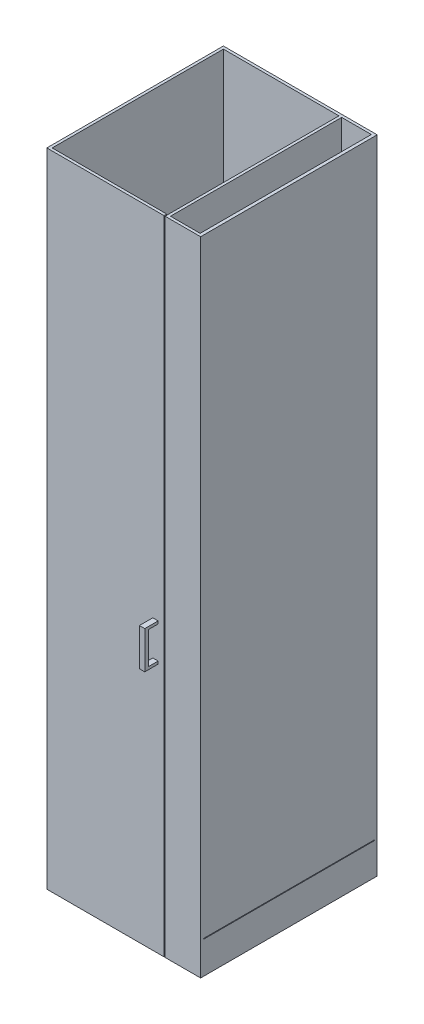
from build123d import *

# Parameters (mm, degrees)
BOSS_EXTRUDE1_DEPTH    = 1200
BOSS_EXTRUDE2_DEPTH    = 320
CUT_EXTRUDE2_START     = 0.5
SKETCH6_W              = 165
SKETCH6_H              = 60
CUT_EXTRUDE2_DEPTH     = 10
BOSS_EXTRUDE14_DEPTH   = 15
LPATTERN1_COUNT        = 2
LPATTERN1_PITCH        = 136
LPATTERN2_COUNT        = 2
LPATTERN2_PITCH        = 75
LPATTERN2_COPY_1_DEPTH = 15
CUT_EXTRUDE5_START     = 70
SKETCH14_R             = 2.5
CUT_EXTRUDE5_DEPTH     = 80
BOSS_EXTRUDE19_DEPTH   = 320
CUT_EXTRUDE10_DEPTH    = 320
BOSS_EXTRUDE20_DEPTH   = 320
CUT_EXTRUDE11_DEPTH    = 320
CUT_EXTRUDE12_DEPTH    = 320
SKETCH32_W             = 66.375164862
SKETCH32_H             = 1200
BOSS_EXTRUDE21_DEPTH   = 5
SKETCH33_W             = 219.088897638
SKETCH33_H             = 1200
BOSS_EXTRUDE23_DEPTH   = 5
SKETCH34_W             = 10
SKETCH34_H             = 70
BOSS_EXTRUDE24_DEPTH   = 30
CUT_EXTRUDE13_REACH    = 91.42
SKETCH35_W             = 18
SKETCH35_H             = 60


with BuildPart() as part:
    # Sketch1 → Boss-Extrude1 (new body)
    with BuildSketch(Plane(origin=(0, 0, 0), x_dir=(1, 0, 0), z_dir=(0, 1, 0))):
        Polygon((-138.29, -160), (-143.29, -160), (-143.29, 165), (144.1740625, 165), (144.1740625, -160), (138.29, -160), (138.29, 160), (-138.29, 160), align=None)
    extrude(amount=BOSS_EXTRUDE1_DEPTH)

    # Sketch3 → Boss-Extrude2 (add)
    with BuildSketch(Plane.XY.offset(-160)):
        Polygon((138.29, 50), (-138.29, 178.971372093), (-138.29, 188.971372093), (138.29, 60), align=None)
    extrude(amount=BOSS_EXTRUDE2_DEPTH)

    # Sketch6 → Cut-Extrude2 (cut)
    with BuildSketch(Plane(origin=(47.680784022, 102.25177131, 0), x_dir=(0.906307787, -0.422618262, 0), z_dir=(0.422618262, 0.906307787, 0)).offset(CUT_EXTRUDE2_START)):
        with Locations((-3.631700195, 0)):
            Rectangle(SKETCH6_W, SKETCH6_H)
    extrude(amount=-CUT_EXTRUDE2_DEPTH, mode=Mode.SUBTRACT)

    # Sketch15 → Boss-Extrude14 (add)
    with BuildSketch(Plane.XY.offset(-30)):
        Polygon((-30.960803737, 128.922945932), (-12.411066849, 120.273061564), (-12.411066849, 105.273061564), (-30.960803737, 113.922945932), align=None)
    boss_extrude14 = extrude(amount=-BOSS_EXTRUDE14_DEPTH)

    # LPattern1: Boss-Extrude14 ×2
    with Locations(*[Vector(0.906307787, -0.422618262, 0) * (i * LPATTERN1_PITCH) for i in range(1, LPATTERN1_COUNT)]):
        add(boss_extrude14)

    # LPattern2: Boss-Extrude14 ×2
    with Locations(*[(0, 0, i * LPATTERN2_PITCH) for i in range(1, LPATTERN2_COUNT)]):
        add(boss_extrude14)

    # LPattern2 copy 1 sketch → LPattern2 copy 1 (add)
    with BuildSketch(Plane(origin=(123.257859037, -57.476083597, 45), x_dir=(1, 0, 0), z_dir=(0, 0, 1))):
        Polygon((-30.960803737, 128.922945932), (-12.411066849, 120.273061564), (-12.411066849, 105.273061564), (-30.960803737, 113.922945932), align=None)
    extrude(amount=-LPATTERN2_COPY_1_DEPTH)

    # Sketch14 → Cut-Extrude5 (cut)
    with BuildSketch(Plane.XY.offset(-30).offset(CUT_EXTRUDE5_START)):
        with Locations((-22.522311936, 121.195788594)):
            Circle(SKETCH14_R)
        with Locations((100.735547101, 63.719704997)):
            Circle(SKETCH14_R)
    extrude(amount=-CUT_EXTRUDE5_DEPTH, mode=Mode.SUBTRACT)

    # Sketch19 → Boss-Extrude19 (add)
    with BuildSketch(Plane.XY.offset(-160)):
        Polygon((82.798897638, 85.875925991), (82.798897638, 1200), (77.798897638, 1200), (77.798897638, 88.207464282), align=None)
    extrude(amount=BOSS_EXTRUDE19_DEPTH)

    # Sketch27 → Cut-Extrude10 (cut)
    with BuildSketch(Plane.XY.offset(160)):
        Polygon((77.798897638, 97.590680412), (82.798897638, 95.259142121), (82.798897638, 85.875925991), (77.798897638, 88.715225589), align=None)
    extrude(amount=-CUT_EXTRUDE10_DEPTH, mode=Mode.SUBTRACT)

    # Sketch28 → Boss-Extrude20 (add)
    with BuildSketch(Plane.XY.offset(160)):
        Polygon((77.798897638, 97.590680412), (83.146994647, 87.403232752), (82.798897638, 95.259142121), align=None)
    extrude(amount=-BOSS_EXTRUDE20_DEPTH)

    # Sketch29 → Cut-Extrude11 (cut)
    with BuildSketch(Plane.XY.offset(160)):
        Polygon((138.29, 60), (138.29, 63), (144.1740625, 61.2), (144.1740625, 60), align=None)
    extrude(amount=-CUT_EXTRUDE11_DEPTH, mode=Mode.SUBTRACT)

    # Sketch31 → Cut-Extrude12 (cut)
    with BuildSketch(Plane.XY.offset(160)):
        Polygon((77.798897638, 88.207464282), (82.798897638, 85.875925991), (77.798897638, 88.715225589), align=None)
    extrude(amount=-CUT_EXTRUDE12_DEPTH, mode=Mode.SUBTRACT)

    # Sketch32 → Boss-Extrude21 (add)
    with BuildSketch(Plane.XY.offset(160)):
        with Locations((110.986480069, 600)):
            Rectangle(SKETCH32_W, SKETCH32_H)
    extrude(amount=BOSS_EXTRUDE21_DEPTH)

    # Sketch33 → Boss-Extrude23 (add)
    with BuildSketch(Plane.XY.offset(160)):
        with Locations((-33.745551181, 600)):
            Rectangle(SKETCH33_W, SKETCH33_H)
    extrude(amount=BOSS_EXTRUDE23_DEPTH)

    # Sketch34 → Boss-Extrude24 (add)
    with BuildSketch(Plane(origin=(0, 0, 160), x_dir=(-1, 0, 0), z_dir=(0, 0, -1))):
        with Locations((-59.754002279, 503.393533755)):
            Rectangle(SKETCH34_W, SKETCH34_H)
    extrude(amount=-BOSS_EXTRUDE24_DEPTH)

    # Sketch35 → Cut-Extrude13 (cut, up to next)
    with BuildSketch(Plane.ZY.offset(-54.754002279), mode=Mode.PRIVATE) as cut_extrude13_sk1:
        with Locations((174, 503.393533755)):
            Rectangle(SKETCH35_W, SKETCH35_H)
    cut_extrude13_tool1 = extrude(cut_extrude13_sk1.sketch, amount=-CUT_EXTRUDE13_REACH, mode=Mode.PRIVATE) & part.part
    add(cut_extrude13_tool1.solids().sort_by_distance((54.754002, 503.393534, 174))[0], mode=Mode.SUBTRACT)


solid = part.part
